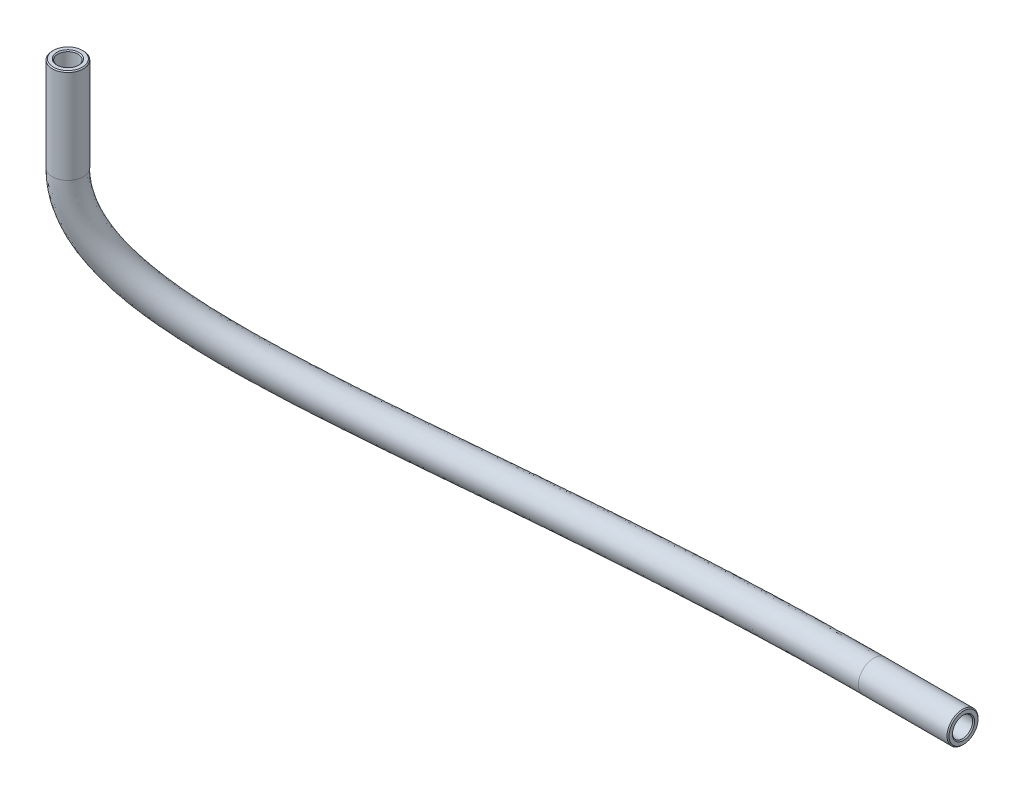
from build123d import *

# Parameters (mm, degrees)
SKETCH1_R     = 2
SKETCH1_R_2   = 1.3
CHAMFER1_SIZE = 0.127


with BuildPart() as part:
    # Sweep1: sweep along a curve in space
    with BuildLine() as sweep1_path:
        Line((156.825, -62.125, 13.85), (156.825, -74.325, 13.85))
        add(Edge.make_bspline(
            [(237.525, -102.482256564, -9.525), (208.592934113, -102.482256564, -9.525), (170.471689747, -97.307145569, 2.1625), (156.825, -82.91748243, 13.85), (156.825, -74.325, 13.85)],
            knots=[0, 0, 0, 0, 0.541354034, 1, 1, 1, 1], degree=3))
        Line((249.105, -102.482256564, -9.525), (237.525, -102.482256564, -9.525))
    # Sketch1 → Sweep1 (sweep)
    with BuildSketch(Plane.ZY.offset(-239.725)):
        with Locations((-9.525, -102.482256564)):
            Circle(SKETCH1_R)
        with Locations((-9.525, -102.482256564)):
            Circle(SKETCH1_R_2, mode=Mode.SUBTRACT)
    sweep(path=sweep1_path.line, is_frenet=True)

    # Chamfer1
    chamfer1_edges = [part.edges().sort_by_distance(p)[0] for p in [
        (249.105, -102.482256564, -10.825),
        (249.105, -102.482256564, -11.525),
        (155.579795583, -62.125, 14.223451416),
        (154.909300897, -62.125, 14.42454064),
    ]]
    chamfer(chamfer1_edges, length=CHAMFER1_SIZE)


solid = part.part
